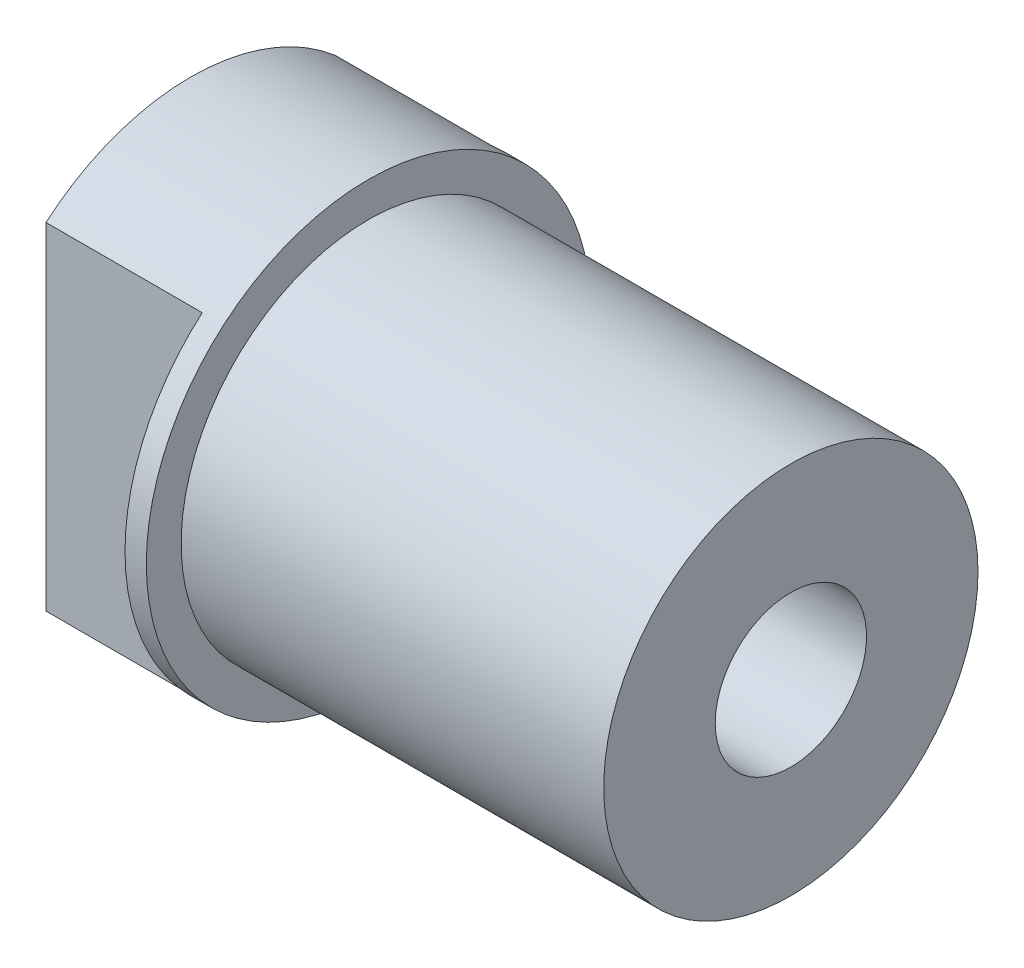
from build123d import *

# Parameters (mm, degrees)
SKETCH2_R               = 7.9375
BOSS_EXTRUDE1_DEPTH     = 6.35
SKETCH3_R               = 6.6929
BOSS_EXTRUDE2_DEPTH     = 15.113
SKETCH4_W               = 5.588
SKETCH4_H               = 2.76225
CUT_EXTRUDE1_DEPTH      = 6.35
F_1_4_28_TAPPED_HOLE1_D = 5.4102


with BuildPart() as part:
    # Sketch2 → Boss-Extrude1 (new body)
    with BuildSketch(Plane(origin=(0, 0, 0), x_dir=(0, 0, -1), z_dir=(1, 0, 0))):
        Circle(SKETCH2_R)
    extrude(amount=-BOSS_EXTRUDE1_DEPTH)

    # Sketch3 → Boss-Extrude2 (add)
    with BuildSketch(Plane(origin=(0, 0, 0), x_dir=(0, 0, -1), z_dir=(1, 0, 0))):
        Circle(SKETCH3_R)
    extrude(amount=BOSS_EXTRUDE2_DEPTH)

    # Sketch4 → Cut-Extrude1 (cut, symmetric)
    with BuildSketch(Plane(origin=(0, 0, 0), x_dir=(1, 0, 0), z_dir=(0, 1, 0))):
        with Locations((-3.556, 6.556375)):
            Rectangle(SKETCH4_W, SKETCH4_H)
        with Locations((-3.556, -6.556375)):
            Rectangle(SKETCH4_W, SKETCH4_H)
    extrude(amount=CUT_EXTRUDE1_DEPTH, both=True, mode=Mode.SUBTRACT)

    # 1/4-28 Tapped Hole1 (through all)
    with Locations(Plane(origin=(-6.35, 0, 0), x_dir=(0, 0, -1), z_dir=(-1, 0, 0))):
        with Locations((0, 0)):
            Hole(F_1_4_28_TAPPED_HOLE1_D / 2)


solid = part.part
